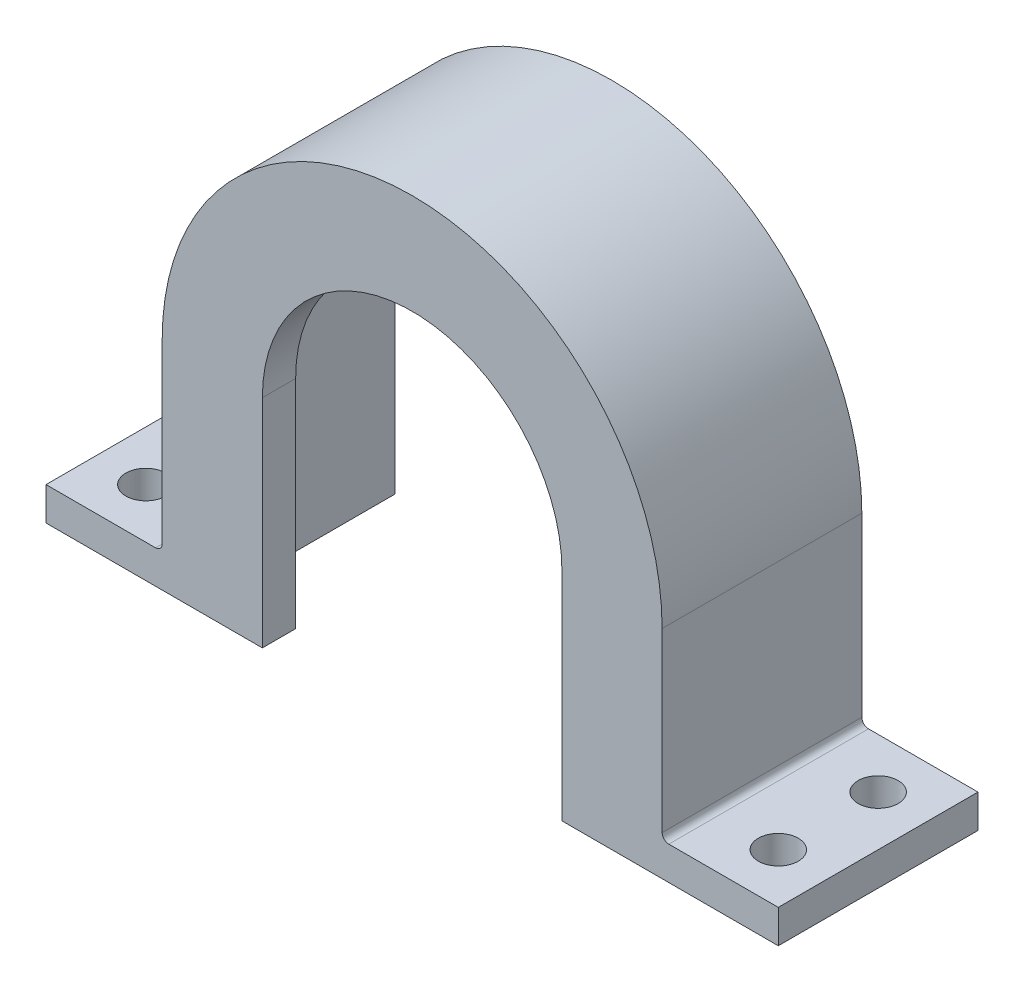
from build123d import *

# Parameters (mm, degrees)
BOSS_EXTRU_1_DEPTH      = 30
ENL_V_MAT_EXTRU_1_DEPTH = 31
ENL_V_MAT_EXTRU_2_DEPTH = 25
ESQUISSE4_R             = 3
ENL_V_MAT_EXTRU_3_DEPTH = 5
CONG_1_R                = 1


with BuildPart() as part:
    # Esquisse1 → Boss.-Extru.1 (new body)
    with BuildSketch(Plane.XY):
        with BuildLine():
            Line((-55, 0), (55, 0))
            Line((55, 0), (55, 5))
            Line((55, 5), (37.55, 5))
            Line((37.55, 5), (37.55, 32.55))
            ThreePointArc((37.55, 32.55), (0, 70.1), (-37.55, 32.55))
            Line((-37.55, 32.55), (-37.55, 5))
            Line((-37.55, 5), (-55, 5))
            Line((-55, 5), (-55, 0))
        make_face()
    extrude(amount=BOSS_EXTRU_1_DEPTH)

    # Esquisse2 → Enlèv. mat.-Extru.1 (cut, through all)
    with BuildSketch(Plane(origin=(0, 0, 0), x_dir=(-1, 0, 0), z_dir=(0, 0, -1))):
        with BuildLine():
            Line((-22.5, 32.55), (-22.5, 0))
            Line((-22.5, 0), (22.5, 0))
            Line((22.5, 0), (22.5, 32.55))
            ThreePointArc((22.5, 32.55), (0, 55.05), (-22.5, 32.55))
        make_face()
    extrude(amount=-ENL_V_MAT_EXTRU_1_DEPTH, mode=Mode.SUBTRACT)

    # Esquisse3 → Enlèv. mat.-Extru.2 (cut)
    with BuildSketch(Plane(origin=(0, 0, 0), x_dir=(-1, 0, 0), z_dir=(0, 0, -1))):
        with BuildLine():
            Line((-32.55, 32.55), (-32.55, 0))
            Line((-32.55, 0), (32.55, 0))
            Line((32.55, 0), (32.55, 32.55))
            ThreePointArc((32.55, 32.55), (0, 65.1), (-32.55, 32.55))
        make_face()
    extrude(amount=-ENL_V_MAT_EXTRU_2_DEPTH, mode=Mode.SUBTRACT)

    # Esquisse4 → Enlèv. mat.-Extru.3 (cut)
    with BuildSketch(Plane.XZ):
        with Locations((47.5, 7.5)):
            Circle(ESQUISSE4_R)
        with Locations((-47.5, 7.5)):
            Circle(ESQUISSE4_R)
        with Locations((47.5, 22.5)):
            Circle(ESQUISSE4_R)
        with Locations((-47.5, 22.5)):
            Circle(ESQUISSE4_R)
    extrude(amount=-ENL_V_MAT_EXTRU_3_DEPTH, mode=Mode.SUBTRACT)

    # Congé1
    cong_1_edges = [part.edges().sort_by_distance(p)[0] for p in [
        (-37.55, 5, 15),
        (37.55, 5, 15),
    ]]
    fillet(cong_1_edges, radius=CONG_1_R)


solid = part.part
